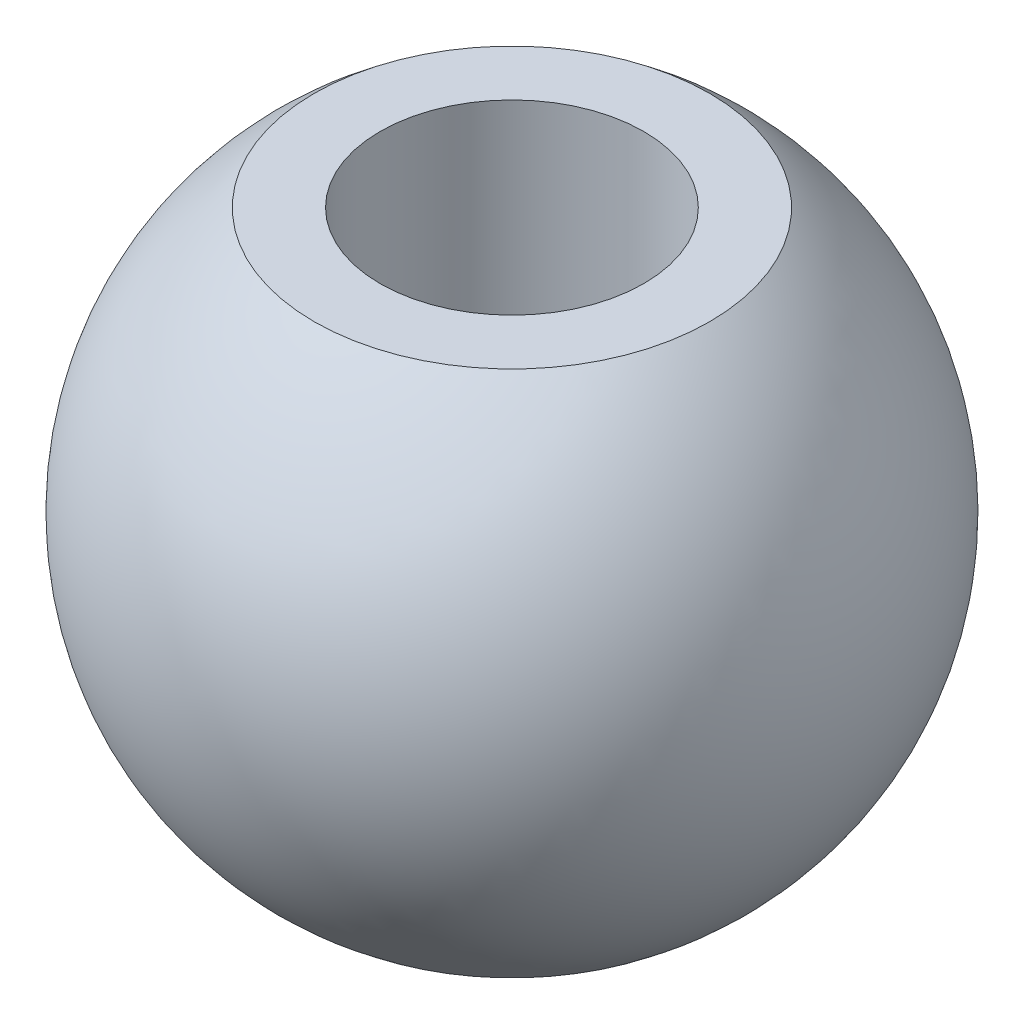
from build123d import *

# Parameters (mm, degrees)
CUT_EXTRUDE1_DEPTH      = 10
CUT_EXTRUDE1_DEPTH_BACK = 10
SKETCH2_W               = 3.001662657
SKETCH2_H               = 0.864450447
SKETCH2_H_2             = 0.90059526
SKETCH3_R               = 1
CUT_EXTRUDE2_DEPTH      = 10


with BuildPart() as part:
    # Sketch1 → Revolve1 (revolve)
    with BuildSketch(Plane(origin=(0, 0, 0), x_dir=(1, 0, 0), z_dir=(0, 1, 0))):
        with BuildLine():
            Line((0, 2.5), (0, -2.5))
            ThreePointArc((0, -2.5), (2.5, 0), (0, 2.5))
        make_face()
    revolve(axis=Axis((0, 0, -2.5), (0, 0, 1)))

    # Sketch2 → Cut-Extrude1 (cut, two sides: drawn at the far end of the back side and taken through both)
    with BuildSketch(Plane.XY.offset(-CUT_EXTRUDE1_DEPTH_BACK)):
        with Locations((0.000831329, -2.432225224)):
            Rectangle(SKETCH2_W, SKETCH2_H)
        with Locations((0.000831329, 2.45029763)):
            Rectangle(SKETCH2_W, SKETCH2_H_2)
    extrude(amount=CUT_EXTRUDE1_DEPTH + CUT_EXTRUDE1_DEPTH_BACK, mode=Mode.SUBTRACT)

    # Sketch3 → Cut-Extrude2 (cut)
    with BuildSketch(Plane.XZ.offset(2)):
        Circle(SKETCH3_R)
    extrude(amount=-CUT_EXTRUDE2_DEPTH, mode=Mode.SUBTRACT)


solid = part.part
